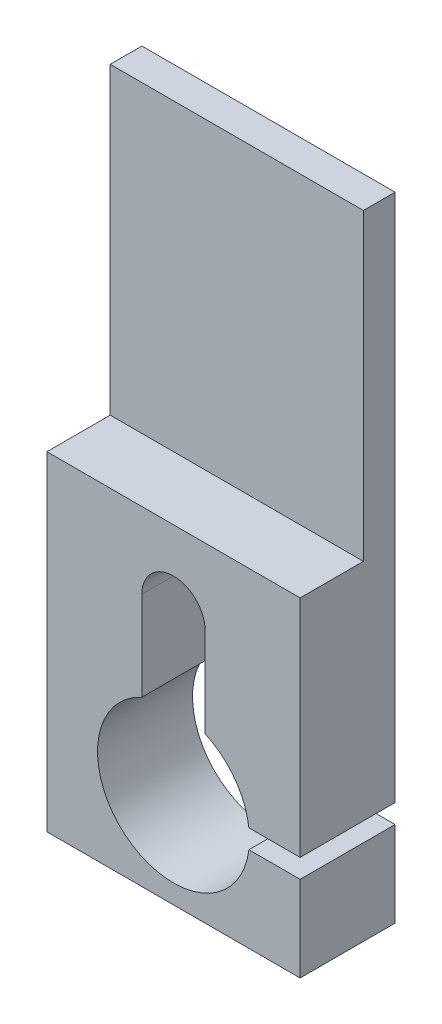
from build123d import *

# Parameters (mm, degrees)
EXTRUSION1_DEPTH = 15
ESQUISSE2_W      = 40
ESQUISSE2_H      = 48
EXTRUSION2_DEPTH = 10


with BuildPart() as part:
    # Esquisse1 → Extrusion1 (new body)
    with BuildSketch(Plane.XY):
        with BuildLine():
            Line((0, 0), (-40, 0))
            Line((-40, 0), (-40, 100))
            Line((-40, 100), (0, 100))
            Line((0, 100), (0, 16.5))
            Line((0, 16.5), (-8.0941191, 16.5))
            ThreePointArc((-8.0941191, 16.5), (-10.32616063, 22.100481099), (-15, 25.908712115))
            Line((-15, 25.908712115), (-15, 40))
            ThreePointArc((-15, 40), (-20, 45), (-25, 40))
            Line((-25, 40), (-25, 25.908712115))
            ThreePointArc((-25, 25.908712115), (-27.100481099, 5.32616063), (-8.0941191, 13.5))
            Line((-8.0941191, 13.5), (0, 13.5))
            Line((0, 13.5), (0, 0))
        make_face()
    extrude(amount=EXTRUSION1_DEPTH)

    # Esquisse2 → Extrusion2 (cut)
    with BuildSketch(Plane.XY.offset(15)):
        with Locations((-20, 76)):
            Rectangle(ESQUISSE2_W, ESQUISSE2_H)
    extrude(amount=-EXTRUSION2_DEPTH, mode=Mode.SUBTRACT)


solid = part.part
